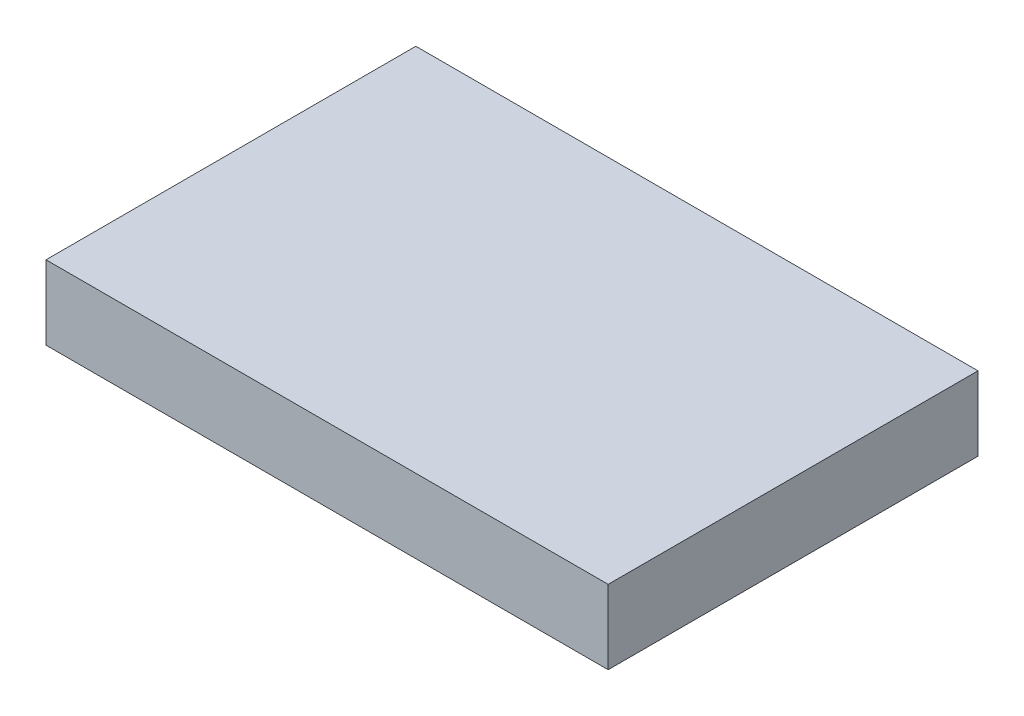
from build123d import *

# Parameters (mm, degrees)
SKETCH1_W           = 38
SKETCH1_H           = 25
BOSS_EXTRUDE1_DEPTH = 5


with BuildPart() as part:
    # Sketch1 → Boss-Extrude1 (new body)
    with BuildSketch(Plane(origin=(0, 0, 0), x_dir=(1, 0, 0), z_dir=(0, 1, 0))):
        with Locations((19, 12.5)):
            Rectangle(SKETCH1_W, SKETCH1_H)
    extrude(amount=BOSS_EXTRUDE1_DEPTH)


solid = part.part
